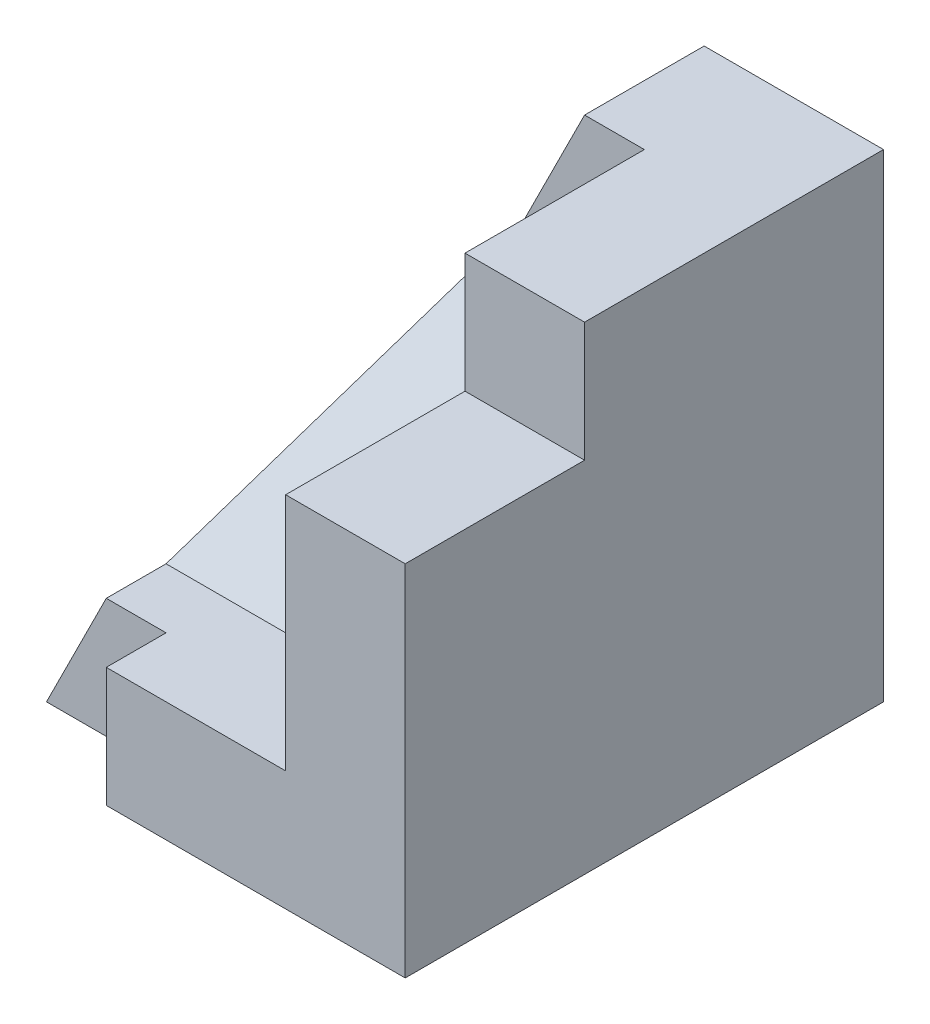
from build123d import *

# Parameters (mm, degrees)
SKETCH1_W           = 35
SKETCH1_H           = 40
BOSS_EXTRUDE1_DEPTH = 40
SKETCH2_W           = 10
SKETCH2_H           = 10
CUT_EXTRUDE1_DEPTH  = 15
SKETCH3_W           = 10
SKETCH3_H           = 10
CUT_EXTRUDE2_DEPTH  = 5
SKETCH4_W           = 25
SKETCH4_H           = 30
CUT_EXTRUDE3_DEPTH  = 10
CUT_EXTRUDE4_DEPTH  = 31
CUT_EXTRUDE5_DEPTH  = 10
CUT_EXTRUDE6_DEPTH  = 20
CUT_EXTRUDE7_DEPTH  = 20


with BuildPart() as part:
    # Sketch1 → Boss-Extrude1 (new body)
    with BuildSketch(Plane.XY):
        Rectangle(SKETCH1_W, SKETCH1_H)
    extrude(amount=BOSS_EXTRUDE1_DEPTH)

    # Sketch2 → Cut-Extrude1 (cut)
    with BuildSketch(Plane.XY.offset(40)):
        with Locations((12.5, 15)):
            Rectangle(SKETCH2_W, SKETCH2_H)
    extrude(amount=-CUT_EXTRUDE1_DEPTH, mode=Mode.SUBTRACT)

    # Sketch3 → Cut-Extrude2 (cut)
    with BuildSketch(Plane.XY.offset(40)):
        with Locations((-12.5, -15)):
            Rectangle(SKETCH3_W, SKETCH3_H)
    extrude(amount=-CUT_EXTRUDE2_DEPTH, mode=Mode.SUBTRACT)

    # Sketch4 → Cut-Extrude3 (cut)
    with BuildSketch(Plane.XY.offset(40)):
        with Locations((-5, 5)):
            Rectangle(SKETCH4_W, SKETCH4_H)
    extrude(amount=-CUT_EXTRUDE3_DEPTH, mode=Mode.SUBTRACT)

    # Sketch5 → Cut-Extrude4 (cut, through all)
    with BuildSketch(Plane.XY.offset(30)):
        Polygon((2.5, 20), (-17.5, -20), (-17.5, 20), align=None)
    extrude(amount=-CUT_EXTRUDE4_DEPTH, mode=Mode.SUBTRACT)

    # Sketch6 → Cut-Extrude5 (cut)
    with BuildSketch(Plane.XY.offset(35)):
        Polygon((-12.5, -10), (-17.5, -20), (-17.5, -10), align=None)
    extrude(amount=-CUT_EXTRUDE5_DEPTH, mode=Mode.SUBTRACT)

    # Sketch7 → Cut-Extrude6 (cut)
    with BuildSketch(Plane.XY.offset(30)):
        Polygon((7.5, 20), (2.5, 20), (-2.5, 10), (7.5, 10), align=None)
    extrude(amount=-CUT_EXTRUDE6_DEPTH, mode=Mode.SUBTRACT)

    # Sketch13 → Cut-Extrude7 (cut)
    with BuildSketch(Plane(origin=(0, 10, 10), x_dir=(1, 0, 0), z_dir=(0, 0.707106781, 0.707106781))):
        Polygon((7.5, 0), (7.5, -28.284271247), (-12.5, -28.284271247), (-2.5, 0), align=None)
    extrude(amount=CUT_EXTRUDE7_DEPTH, mode=Mode.SUBTRACT)


solid = part.part
